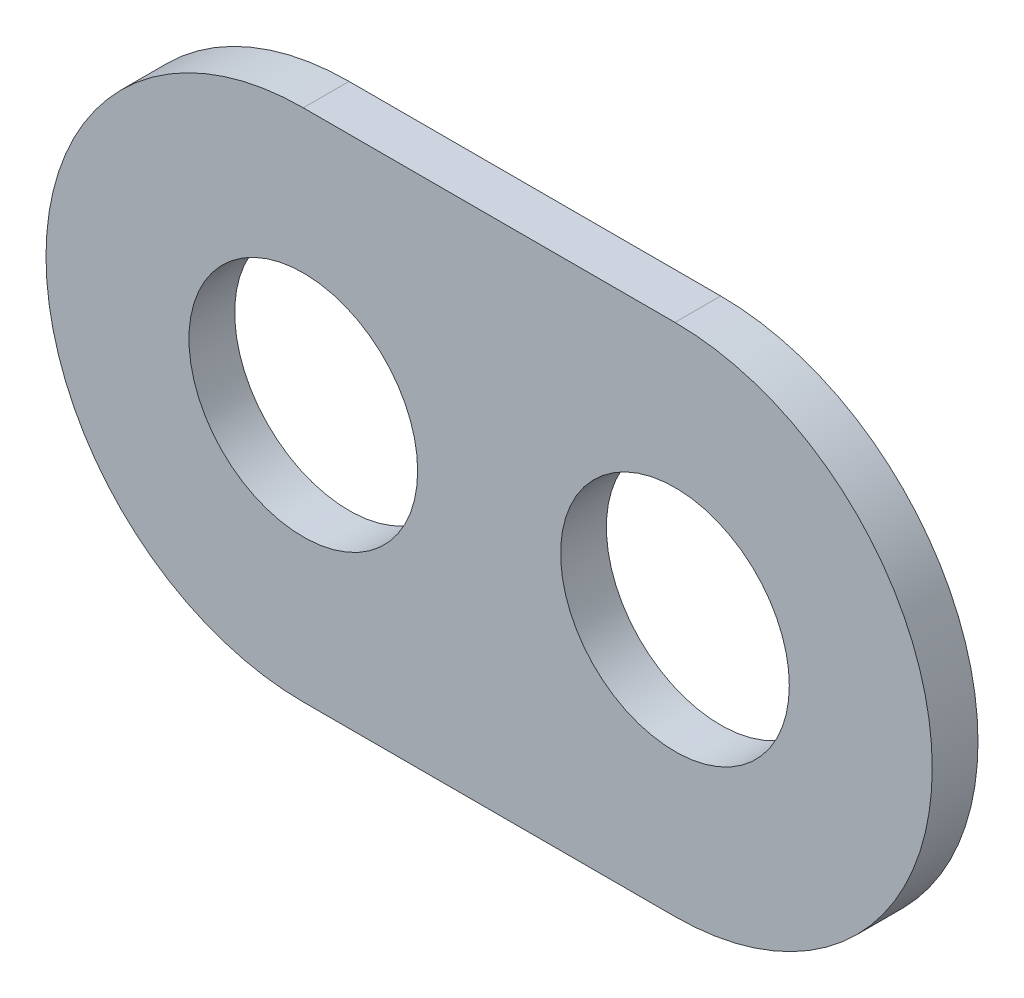
from build123d import *

# Parameters (mm, degrees)
SKETCH1_R           = 8
BOSS_EXTRUDE1_DEPTH = 3.2


with BuildPart() as part:
    # Sketch1 → Boss-Extrude1 (new body)
    with BuildSketch(Plane.XY):
        with BuildLine():
            Line((-13, 18), (13, 18))
            ThreePointArc((13, 18), (31, 0), (13, -18))
            Line((13, -18), (-13, -18))
            ThreePointArc((-13, -18), (-31, 0), (-13, 18))
        make_face()
        with Locations((-13, 0)):
            Circle(SKETCH1_R, mode=Mode.SUBTRACT)
        with Locations((13, 0)):
            Circle(SKETCH1_R, mode=Mode.SUBTRACT)
    extrude(amount=BOSS_EXTRUDE1_DEPTH)


solid = part.part
